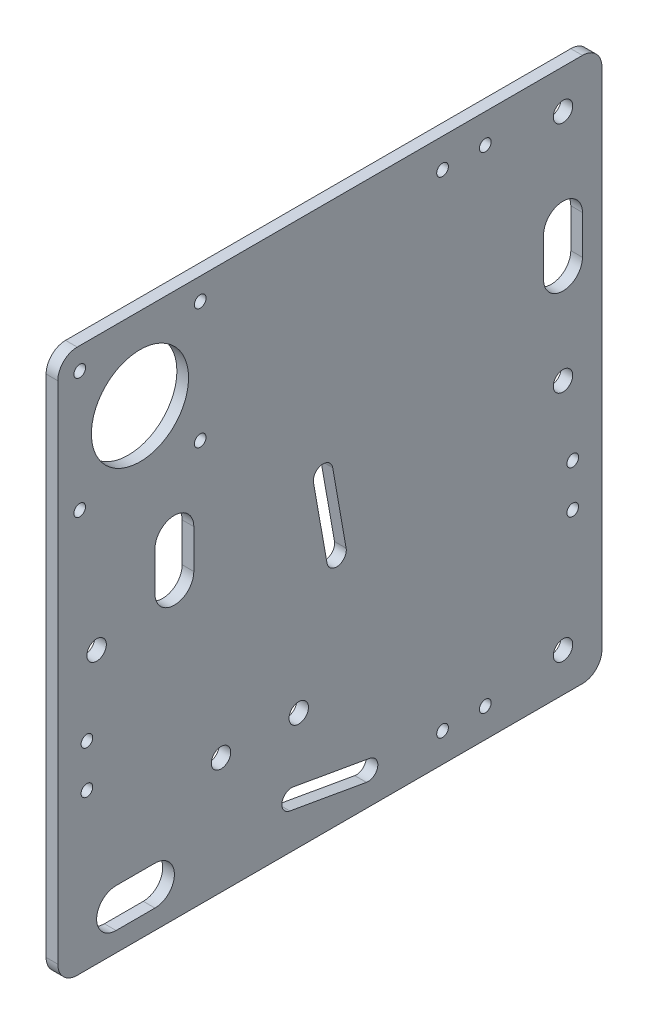
from build123d import *

# Parameters (mm, degrees)
SKETCH1_W                               = 140
SKETCH1_H                               = 140
BASE_PLATE_DEPTH                        = 3
BASE_PLATE_CORNER_ROUNDING_R            = 5
SKETCH2_R                               = 2.5
V_WHEEL_SLOTS_AND_HOLES_DEPTH           = 4
SKETCH4_R                               = 1.5
MOTOR_MOUNT_HOLES_DEPTH                 = 4
MOTOR_MOUNT_HOLES_PATTERN_COUNT         = 2
MOTOR_MOUNT_HOLES_PATTERN_PITCH         = 31
MOTOR_MOUNT_HOLES_PATTERN_COUNT_DIR2    = 2
MOTOR_MOUNT_HOLES_PATTERN_PITCH_DIR2    = 31
SKETCH5_R                               = 12.5
MOTOR_HOLE_DEPTH                        = 4
SKETCH6_R                               = 2.5
THREADED_ROD_BLOCK_MOUNTING_HOLES_DEPTH = 4
SKETCH7_R                               = 1.5
ENDSTOP_MOUNTING_HOLES_DEPTH            = 4
WIRE_ROUTING_SLOTS_DEPTH                = 4


with BuildPart() as part:
    # Sketch1 → Base Plate (new body)
    with BuildSketch(Plane(origin=(0, 0, 0), x_dir=(0, 0, -1), z_dir=(1, 0, 0))):
        with Locations((0, 70)):
            Rectangle(SKETCH1_W, SKETCH1_H)
    extrude(amount=BASE_PLATE_DEPTH)

    # Base Plate Corner Rounding
    base_plate_corner_rounding_edges = [part.edges().sort_by_distance(p)[0] for p in [
        (1.5, 140, 70),
        (1.5, 140, -70),
        (1.5, 0, -70),
        (1.5, 0, 70),
    ]]
    fillet(base_plate_corner_rounding_edges, radius=BASE_PLATE_CORNER_ROUNDING_R)

    # Sketch2 → V Wheel Slots and Holes (cut, through all)
    with BuildSketch(Plane(origin=(3, 0, 0), x_dir=(0, 0, -1), z_dir=(1, 0, 0))):
        with Locations((60, 70)):
            Circle(SKETCH2_R)
        with Locations((-60, 70)):
            Circle(SKETCH2_R)
        with Locations((60, 10)):
            Circle(SKETCH2_R)
        with Locations((60, 130)):
            Circle(SKETCH2_R)
        with BuildLine():
            Line((-9.413957086, 14.198501159), (10.282197974, 10.725537606))
            ThreePointArc((10.282197974, 10.725537606), (12.310096913, 7.829397779), (9.413957086, 5.801498841))
            Line((9.413957086, 5.801498841), (-10.282197974, 9.274462394))
            ThreePointArc((-10.282197974, 9.274462394), (-12.310096913, 12.170602221), (-9.413957086, 14.198501159))
        make_face()
        with BuildLine():
            Line((0.725537606, 80.282197974), (4.198501159, 60.586042914))
            ThreePointArc((4.198501159, 60.586042914), (2.170602221, 57.689903087), (-0.725537606, 59.717802026))
            Line((-0.725537606, 59.717802026), (-4.198501159, 79.413957086))
            ThreePointArc((-4.198501159, 79.413957086), (-2.170602221, 82.310096913), (0.725537606, 80.282197974))
        make_face()
    extrude(amount=-V_WHEEL_SLOTS_AND_HOLES_DEPTH, mode=Mode.SUBTRACT)

    # Sketch4 → Motor Mount Holes (cut, through all)
    with BuildSketch(Plane(origin=(3, 0, 0), x_dir=(0, 0, -1), z_dir=(1, 0, 0))):
        with Locations((-64.35, 134.35)):
            Circle(SKETCH4_R)
    motor_mount_holes = extrude(amount=-MOTOR_MOUNT_HOLES_DEPTH, mode=Mode.SUBTRACT)

    # Motor Mount Holes Pattern: Motor Mount Holes 2 × 2
    with Locations(*[(0, -j * MOTOR_MOUNT_HOLES_PATTERN_PITCH_DIR2, -i * MOTOR_MOUNT_HOLES_PATTERN_PITCH) for i in range(MOTOR_MOUNT_HOLES_PATTERN_COUNT) for j in range(MOTOR_MOUNT_HOLES_PATTERN_COUNT_DIR2) if (i, j) != (0, 0)]):
        add(motor_mount_holes, mode=Mode.SUBTRACT)

    # Sketch5 → Motor Hole (cut, through all)
    with BuildSketch(Plane(origin=(3, 0, 0), x_dir=(0, 0, -1), z_dir=(1, 0, 0))):
        with Locations((-48.85, 118.85)):
            Circle(SKETCH5_R)
    extrude(amount=-MOTOR_HOLE_DEPTH, mode=Mode.SUBTRACT)

    # Sketch6 → Threaded Rod Block Mounting Holes (cut, through all)
    with BuildSketch(Plane(origin=(3, 0, 0), x_dir=(0, 0, -1), z_dir=(1, 0, 0))):
        with Locations((-8, 30)):
            Circle(SKETCH6_R)
        with Locations((-28, 30)):
            Circle(SKETCH6_R)
    extrude(amount=-THREADED_ROD_BLOCK_MOUNTING_HOLES_DEPTH, mode=Mode.SUBTRACT)

    # Sketch7 → Endstop Mounting Holes (cut, through all)
    with BuildSketch(Plane(origin=(3, 0, 0), x_dir=(0, 0, -1), z_dir=(1, 0, 0))):
        with Locations((-62.5, 51)):
            Circle(SKETCH7_R)
        with Locations((-62.5, 40)):
            Circle(SKETCH7_R)
        with Locations((62.5, 51)):
            Circle(SKETCH7_R)
        with Locations((62.5, 40)):
            Circle(SKETCH7_R)
        with Locations((40, 132.5)):
            Circle(SKETCH7_R)
        with Locations((29, 132.5)):
            Circle(SKETCH7_R)
        with Locations((40, 7.5)):
            Circle(SKETCH7_R)
        with Locations((29, 7.5)):
            Circle(SKETCH7_R)
    extrude(amount=-ENDSTOP_MOUNTING_HOLES_DEPTH, mode=Mode.SUBTRACT)

    # Sketch8 → Wire Routing Slots (cut, through all)
    with BuildSketch(Plane(origin=(3, 0, 0), x_dir=(0, 0, -1), z_dir=(1, 0, 0))):
        with BuildLine():
            Line((65, 105), (65, 95))
            ThreePointArc((65, 95), (60, 90), (55, 95))
            Line((55, 95), (55, 105))
            ThreePointArc((55, 105), (60, 110), (65, 105))
        make_face()
        with BuildLine():
            Line((-35, 85), (-35, 75))
            ThreePointArc((-35, 75), (-40, 70), (-45, 75))
            Line((-45, 75), (-45, 85))
            ThreePointArc((-45, 85), (-40, 90), (-35, 85))
        make_face()
        with BuildLine():
            Line((-55, 15), (-45, 15))
            ThreePointArc((-45, 15), (-40, 10), (-45, 5))
            Line((-45, 5), (-55, 5))
            ThreePointArc((-55, 5), (-60, 10), (-55, 15))
        make_face()
    extrude(amount=-WIRE_ROUTING_SLOTS_DEPTH, mode=Mode.SUBTRACT)


solid = part.part
